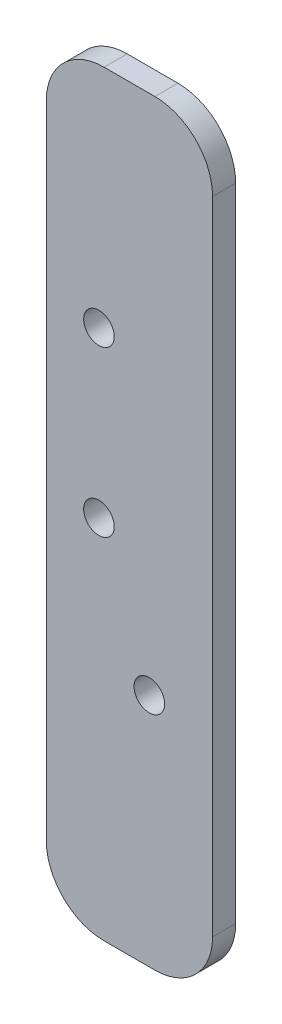
from build123d import *

# Parameters (mm, degrees)
SKETCH1_W            = 28.802861634
SKETCH1_H            = 131.078546172
BOSS_EXTRUDE1_DEPTH  = 4
M5_CLEARANCE_HOLE1_D = 5.3
FILLET1_R            = 10
M5_CLEARANCE_HOLE2_D = 5.3


with BuildPart() as part:
    # Sketch1 → Boss-Extrude1 (new body)
    with BuildSketch(Plane.XY):
        with Locations((-48.87450938, -319.394379884)):
            Rectangle(SKETCH1_W, SKETCH1_H)
    extrude(amount=BOSS_EXTRUDE1_DEPTH)

    # M5 Clearance Hole1 (through all)
    with Locations(Plane.XY.offset(4)):
        with Locations((-54.16270611, -321.915681156), (-54.16270611, -293.415681156)):
            Hole(M5_CLEARANCE_HOLE1_D / 2)

    # Fillet1
    fillet1_edges = [part.edges().sort_by_distance(p)[0] for p in [
        (-63.275940197, -253.855106798, 2),
        (-34.473078563, -253.855106798, 2),
        (-34.473078563, -384.93365297, 2),
        (-63.275940197, -384.93365297, 2),
    ]]
    fillet(fillet1_edges, radius=FILLET1_R)

    # M5 Clearance Hole2 (through all)
    with Locations(Plane(origin=(0, 0, 0), x_dir=(-1, 0, 0), z_dir=(0, 0, -1))):
        with Locations((45.426427008, -344.165502047)):
            Hole(M5_CLEARANCE_HOLE2_D / 2)


solid = part.part
